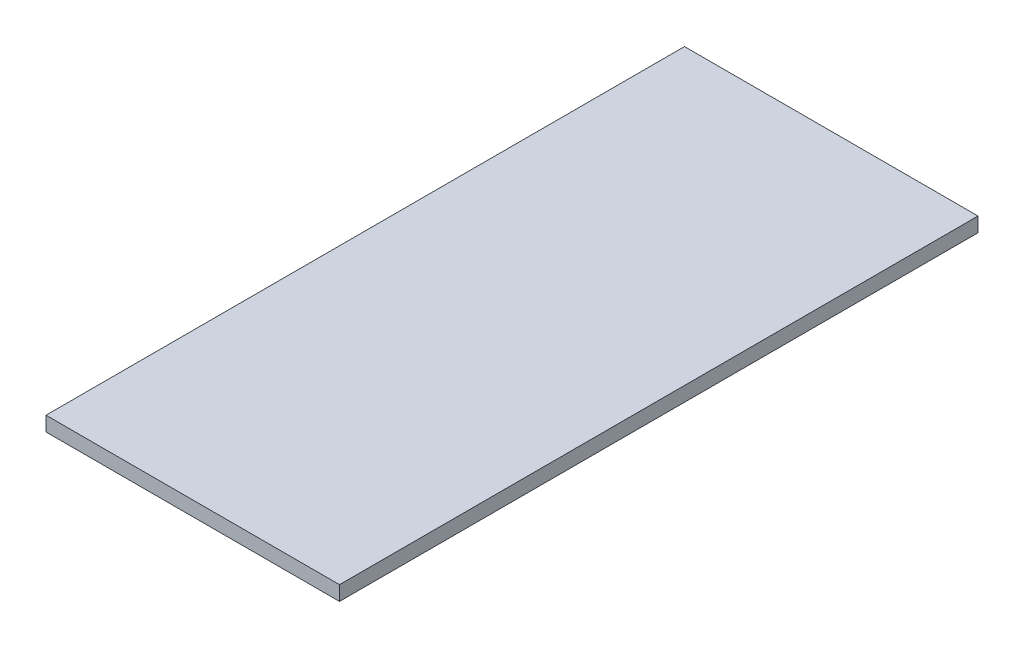
from build123d import *

# Parameters (mm, degrees)
SKETCH1_W           = 221.93400162
SKETCH1_H           = 482.821743015
BOSS_EXTRUDE1_DEPTH = 11


with BuildPart() as part:
    # Sketch1 → Boss-Extrude1 (new body)
    with BuildSketch(Plane.XZ.offset(-39.604714467)):
        with Locations((8.267412509, 290.587581363)):
            Rectangle(SKETCH1_W, SKETCH1_H)
    extrude(amount=BOSS_EXTRUDE1_DEPTH)


solid = part.part
